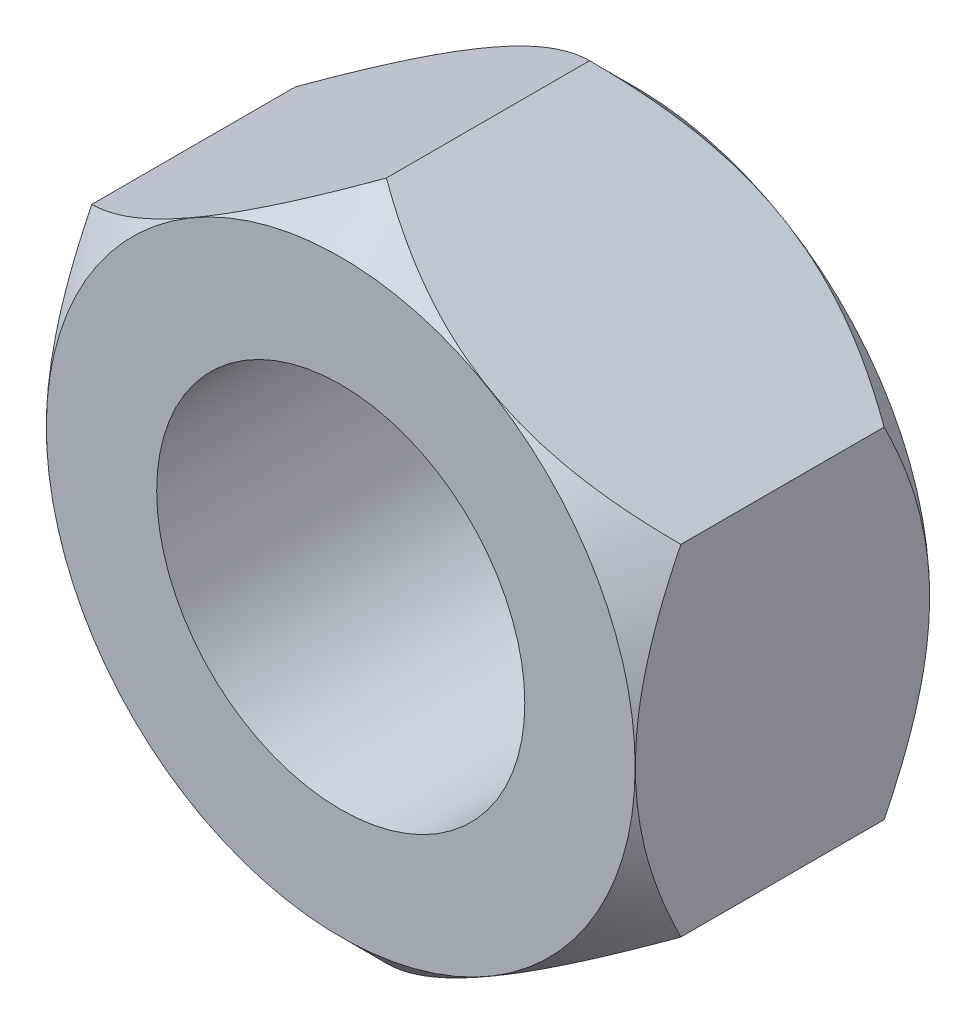
from build123d import *

# Parameters (mm, degrees)
EXTRUDE_1_DEPTH     = 4
SKETCH_2_R          = 2.5
CUT_EXTRUDE_1_DEPTH = 4
FILLET_1_R          = 0.1


with BuildPart() as part:
    # 草图1 → 凸台-拉伸1 (new body)
    with BuildSketch(Plane.XY):
        Polygon((0, 4.618802154), (-4, 2.309401077), (-4, -2.309401077), (0, -4.618802154), (4, -2.309401077), (4, 2.309401077), align=None)
    extrude(amount=EXTRUDE_1_DEPTH)

    # 草图2 → 切除-拉伸1 (cut)
    with BuildSketch(Plane.XY.offset(4)):
        Circle(SKETCH_2_R)
    extrude(amount=-CUT_EXTRUDE_1_DEPTH, mode=Mode.SUBTRACT)

    # 圆角1
    fillet_1_edges = [part.edges().sort_by_distance(p)[0] for p in [
        (-2.5, 0, 0),
    ]]
    fillet(fillet_1_edges, radius=FILLET_1_R)

    # 草图3 → 切除-旋转2 (revolve, cut)
    with BuildSketch(Plane(origin=(0, 0, 0), x_dir=(0, 0, -1), z_dir=(1, 0, 0))):
        Polygon((0, 4.618802154), (0, 3.998802154), (-0.62, 4.618802154), align=None)
        Polygon((-3.38, 4.618802154), (-4, 3.998802154), (-4, 4.618802154), align=None)
    revolve(axis=Axis((0, 0, 0), (0, 0, -1)), mode=Mode.SUBTRACT)


solid = part.part
